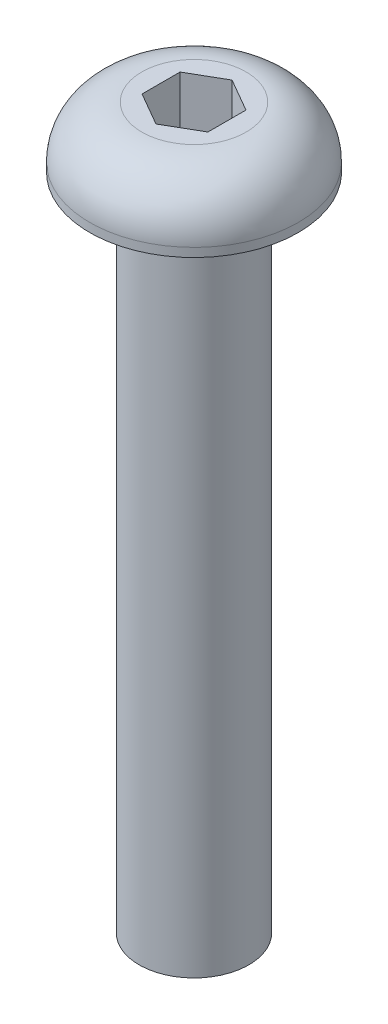
from build123d import *

# Parameters (mm, degrees)
CORTE_EXTRUS_O1_DEPTH = 4


with BuildPart() as part:
    # Esboço1 → Revolução1 (revolve)
    with BuildSketch(Plane.XY):
        with BuildLine():
            Line((0, 0), (2.5, 0))
            Line((2.5, 0), (2.5, 30))
            Line((2.5, 30), (4.75, 30))
            Line((4.75, 30), (4.75, 30.4))
            ThreePointArc((4.75, 30.4), (4.054378605, 32.079378605), (2.375, 32.775))
            Line((2.375, 32.775), (0, 32.775))
            Line((0, 32.775), (0, 0))
        make_face()
    revolve(axis=Axis((0, 32.775, 0), (0, -1, 0)))

    # Esboço2 → Corte-extrusão1 (cut)
    with BuildSketch(Plane(origin=(0, 32.775, 0), x_dir=(1, 0, 0), z_dir=(0, 1, 0))):
        Polygon((-1.5, 0.866025404), (-1.5, -0.866025404), (0, -1.732050808), (1.5, -0.866025404), (1.5, 0.866025404), (0, 1.732050808), align=None)
    extrude(amount=-CORTE_EXTRUS_O1_DEPTH, mode=Mode.SUBTRACT)


solid = part.part
